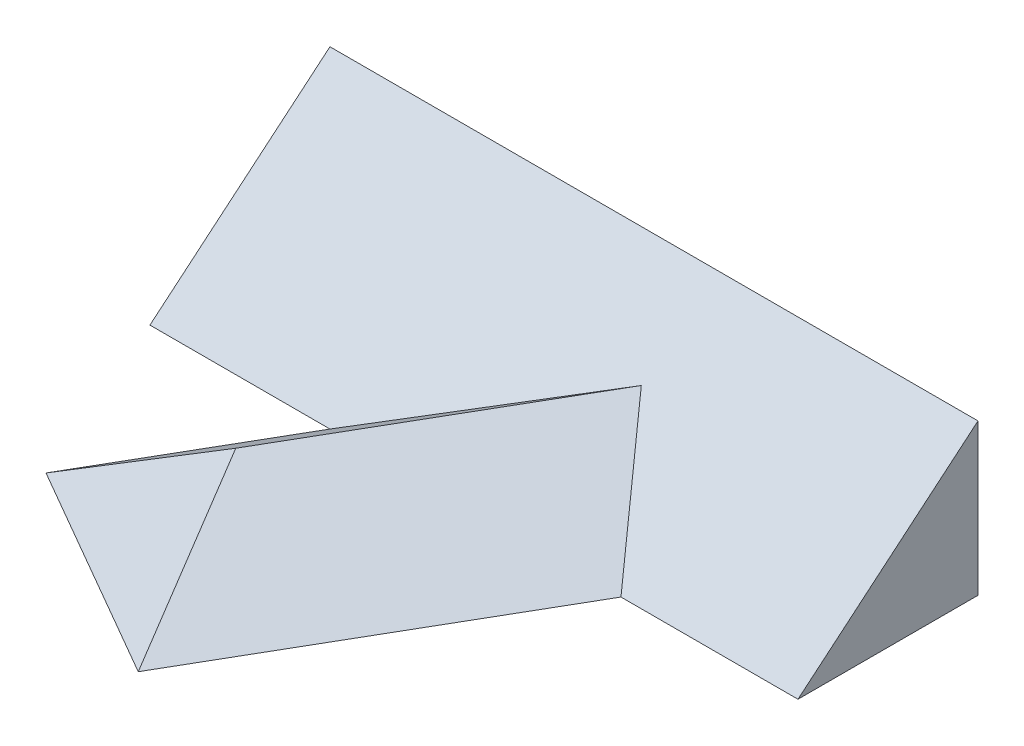
from build123d import *

# Parameters (mm, degrees)
EXTRUDE1_DEPTH     = 180
EXTRUDE2_DEPTH     = 115
CUT_EXTRUDE1_DEPTH = 35


with BuildPart() as part:
    # Sketch1 → Extrude1 (new body)
    with BuildSketch(Plane(origin=(0, 0, 0), x_dir=(0, 0, -1), z_dir=(1, 0, 0))):
        Polygon((0, 0), (50, 0), (50, 41.954981559), align=None)
    extrude(amount=EXTRUDE1_DEPTH)

    # Sketch5 → Extrude2 (add)
    with BuildSketch(Plane(origin=(-16.367513459, 0, 28.349364905), x_dir=(0.866025404, 0, 0.5), z_dir=(-0.5, 0, 0.866025404))):
        Polygon((43.301270189, 0), (78.301270189, 24.507263837), (113.301270189, 0), align=None)
    extrude(amount=-EXTRUDE2_DEPTH)

    # Sketch6 → Cut-Extrude1 (cut, symmetric)
    with BuildSketch(Plane(origin=(51.443375673, 0, 67.5), x_dir=(0.5, 0, -0.866025404), z_dir=(0.866025404, 0, 0.5))):
        Polygon((29.206619723, 24.507263837), (0, 24.507263837), (0, 0), align=None)
    extrude(amount=CUT_EXTRUDE1_DEPTH, both=True, mode=Mode.SUBTRACT)


solid = part.part
